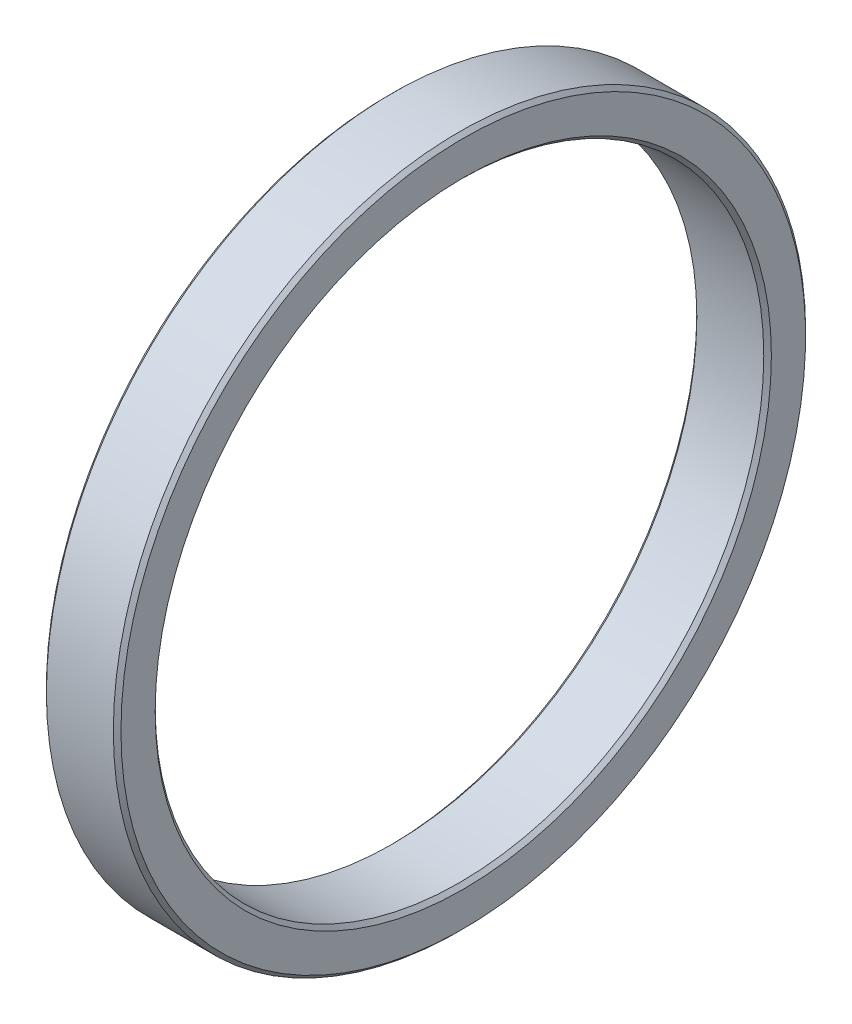
from build123d import *

# Parameters (mm, degrees)
SKETCH1_W     = 9.8
SKETCH1_H     = 5.5
CHAMFER1_SIZE = 0.5


with BuildPart() as part:
    # Sketch1 → Revolve1 (revolve)
    with BuildSketch(Plane.XY):
        with Locations((4.9, 42.75)):
            Rectangle(SKETCH1_W, SKETCH1_H)
    revolve(axis=Axis((0, 0, 0), (1, 0, 0)))

    # Chamfer1
    chamfer1_edges = [part.edges().sort_by_distance(p)[0] for p in [
        (0, -45.5, 0),
        (9.8, -45.5, 0),
        (9.8, -40, 0),
        (0, -40, 0),
    ]]
    chamfer(chamfer1_edges, length=CHAMFER1_SIZE)


solid = part.part
